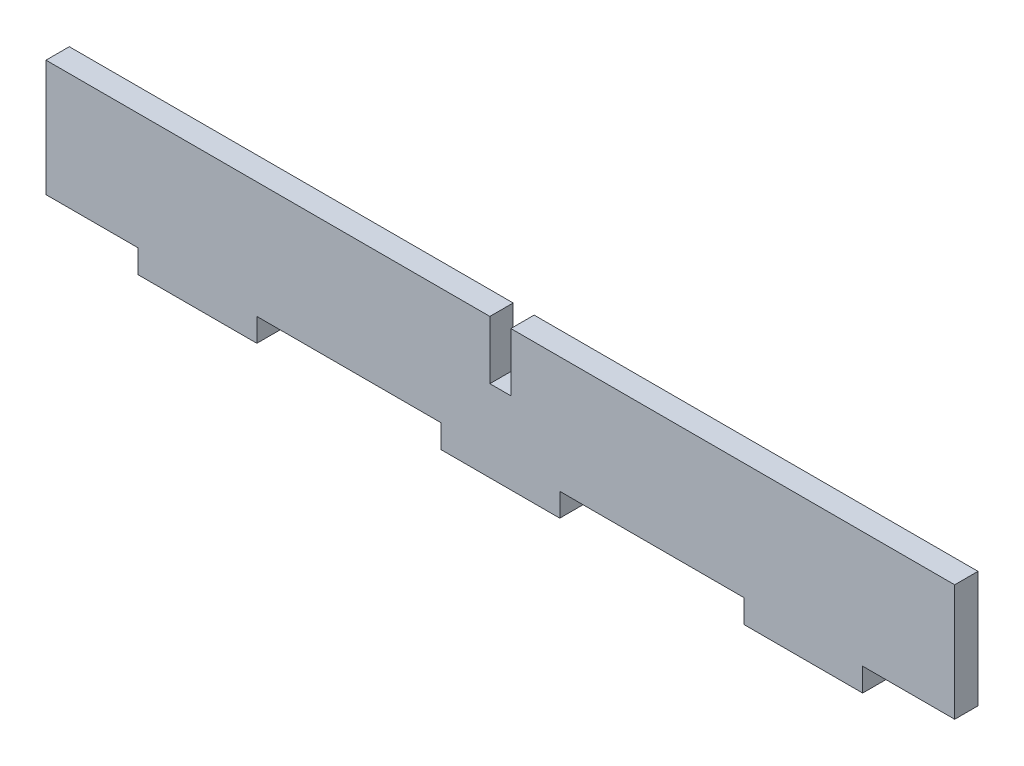
from build123d import *

# Parameters (mm, degrees)
EXTRUDE_1_DEPTH = 2


with BuildPart() as part:
    # 草圖1 → 填料-伸長1 (new body)
    with BuildSketch(Plane.XY):
        Polygon((-39, 2), (-31.1, 2), (-31.1, 0), (-20.9, 0), (-20.9, 2), (-5.1, 2), (-5.1, 0), (5.1, 0), (5.1, 2), (20.9, 2), (20.9, 0), (31.1, 0), (31.1, 2), (39, 2), (39, 12), (0.9, 12), (0.9, 7), (-0.9, 7), (-0.9, 12), (-39, 12), align=None)
    extrude(amount=EXTRUDE_1_DEPTH)


solid = part.part
